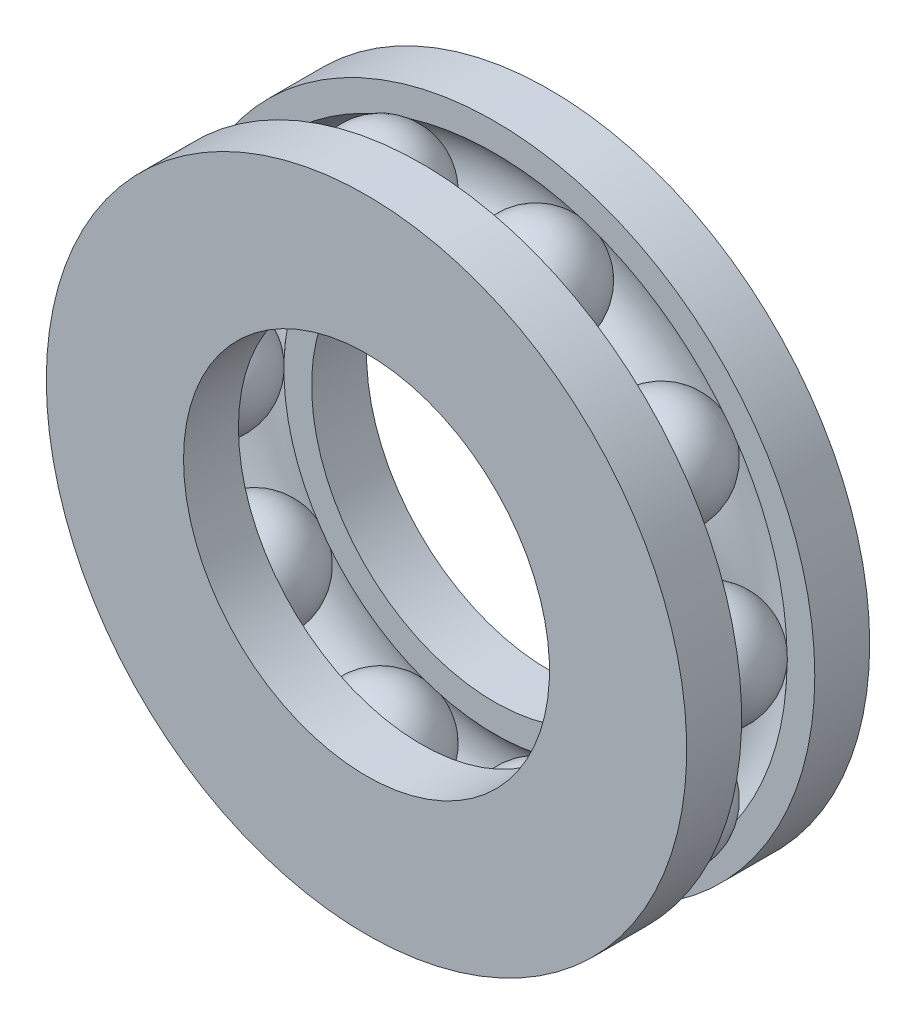
from build123d import *

# Parameters (mm, degrees)
SKETCH1_R           = 17.5
SKETCH1_R_2         = 10
BOSS_EXTRUDE1_DEPTH = 3
SKETCH3_R           = 17.5
SKETCH3_R_2         = 10
BOSS_EXTRUDE2_DEPTH = 3
SKETCH2_R           = 3
CIRPATTERN6_COUNT   = 10


with BuildPart() as part:
    # Sketch1 → Boss-Extrude1 (new body)
    with BuildSketch(Plane.XY):
        Circle(SKETCH1_R)
        Circle(SKETCH1_R_2, mode=Mode.SUBTRACT)
    extrude(amount=BOSS_EXTRUDE1_DEPTH)


with BuildPart() as body_2:
    # Sketch3 → Boss-Extrude2 (new body)
    with BuildSketch(Plane(origin=(0, 0, 10), x_dir=(-1, 0, 0), z_dir=(0, 0, -1))):
        Circle(SKETCH3_R)
        Circle(SKETCH3_R_2, mode=Mode.SUBTRACT)
    extrude(amount=BOSS_EXTRUDE2_DEPTH)


with BuildPart() as cut_revolve1_tool:
    # Sketch2 → Cut-Revolve1 (revolve)
    with BuildSketch(Plane(origin=(0, 0, 0), x_dir=(1, 0, 0), z_dir=(0, 1, 0))):
        with Locations((-13.75, -5)):
            Circle(SKETCH2_R)
    revolve(axis=Axis((0, 0, 0), (0, 0, 1)))


with BuildPart() as part_1:
    add(part.part)

    # Cut-Revolve1: cut by cut_revolve1_tool
    add(cut_revolve1_tool.part, mode=Mode.SUBTRACT)


with BuildPart() as body_2_1:
    add(body_2.part)

    # Cut-Revolve1: cut by cut_revolve1_tool
    add(cut_revolve1_tool.part, mode=Mode.SUBTRACT)


with BuildPart() as body_3:
    # Sketch4 → Revolve1 (revolve)
    with BuildSketch(Plane(origin=(0, 0, 0), x_dir=(1, 0, 0), z_dir=(0, 1, 0))):
        with BuildLine():
            Line((-13.75, -8.01), (-13.75, -1.99))
            ThreePointArc((-13.75, -1.99), (-16.76, -5), (-13.75, -8.01))
        make_face()
    revolve1 = revolve(axis=Axis((-13.75, 0, 9.678831593), (0, 0, -1)))


with BuildPart() as part_2:
    add(part_1.part)

    add(body_2_1.part)  # CirPattern6 merges body 2
    # CirPattern6: Revolve1 ×10 about axis
    cirpattern6_axis = Axis((0, 0, 0), (0, 0, 1))
    for i in range(1, CIRPATTERN6_COUNT):
        add(revolve1.rotate(cirpattern6_axis, i * 360 / CIRPATTERN6_COUNT))


solid = Compound([body_3.part, part_2.part])
